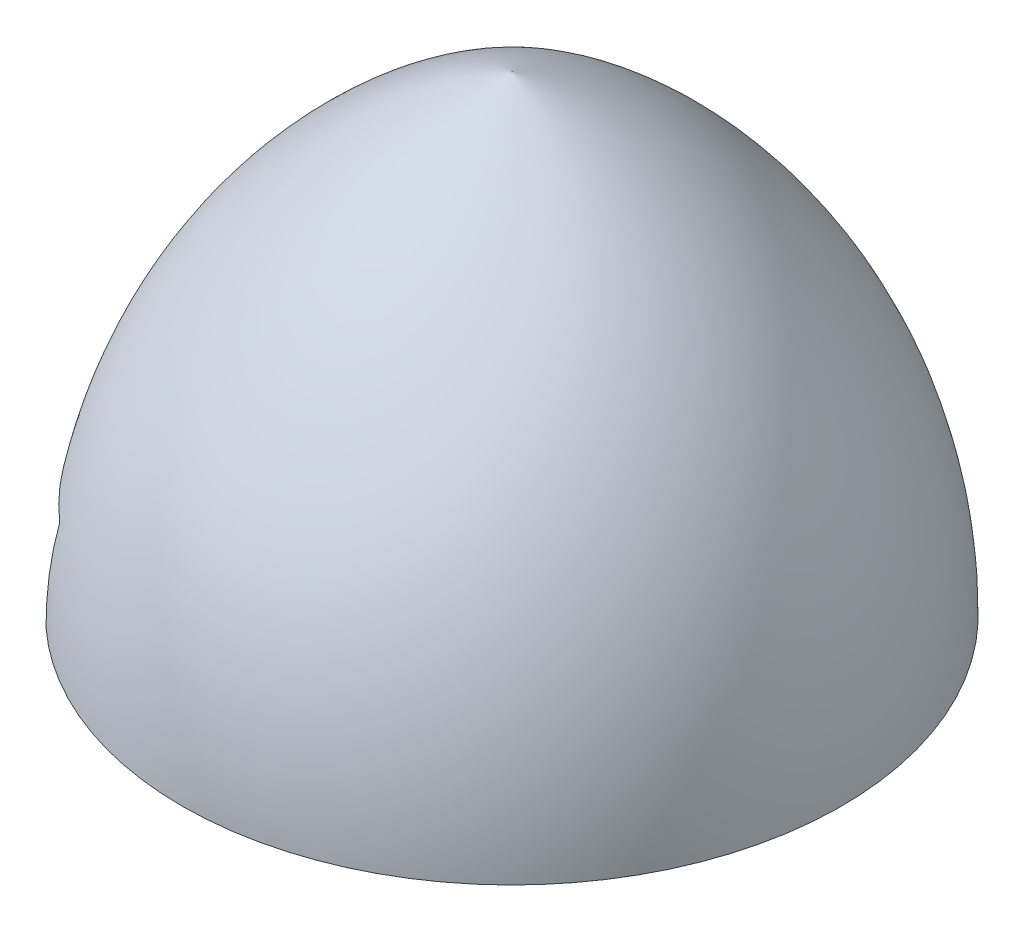
from build123d import *

# Parameters (mm, degrees)
SKETCH2_R          = 1
CUT_EXTRUDE1_DEPTH = 4
CHAMFER1_SIZE      = 1
CUT_EXTRUDE4_DEPTH = 1.02


with BuildPart() as part:
    # Sketch1 → Revolve1 (revolve)
    with BuildSketch(Plane(origin=(0, 0, 0), x_dir=(0, 0, -1), z_dir=(1, 0, 0))):
        with BuildLine():
            Line((0, 5), (0, 0))
            Line((0, 0), (-3.5, 0))
            ThreePointArc((-3.5, 0), (-2.538055577, 3.051638904), (0, 5))
        make_face()
    revolve(axis=Axis((0, 0, 0), (0, -1, 0)))

    # Sketch2 → Cut-Extrude1 (cut)
    with BuildSketch(Plane.XZ):
        Circle(SKETCH2_R)
    extrude(amount=-CUT_EXTRUDE1_DEPTH, mode=Mode.SUBTRACT)

    # Chamfer1
    chamfer1_edges = [part.edges().sort_by_distance(p)[0] for p in [
        (-1, 4, 0),
    ]]
    chamfer(chamfer1_edges, length=CHAMFER1_SIZE)

    # Sketch4 → Cut-Extrude4 (cut)
    with BuildSketch(Plane(origin=(0, 0, 0), x_dir=(1, 0, 0), z_dir=(0, 1, 0))):
        with BuildLine():
            Line((-3.5, 2.75), (1, 2.077470494))
            ThreePointArc((1, 2.077470494), (2.790063101, 0), (1, -2.077470494))
            Line((1, -2.077470494), (-3.5, -2.75))
            Line((-3.5, -2.75), (-3.5, -0.75))
            ThreePointArc((-3.5, -0.75), (-2.75, 0), (-3.5, 0.75))
            Line((-3.5, 0.75), (-3.5, 2.75))
        make_face()
    extrude(amount=CUT_EXTRUDE4_DEPTH, mode=Mode.SUBTRACT)


solid = part.part
